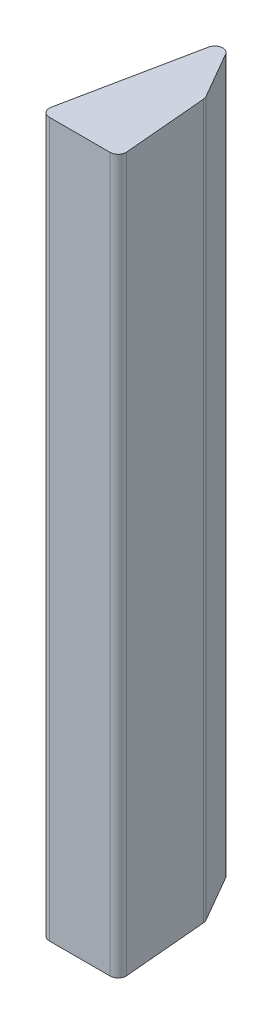
from build123d import *

# Parameters (mm, degrees)
EXTRUDE_1_DEPTH = 450


with BuildPart() as part:
    # Эскиз1 → Бобышка-Вытянуть1 (new body)
    with BuildSketch(Plane(origin=(0, 0, 0), x_dir=(1, 0, 0), z_dir=(0, 1, 0))):
        with BuildLine():
            Line((-43.879004349, 0), (-5.456542505, 0))
            ThreePointArc((-5.456542505, 0), (-1.770155821, 1.622048962), (-0.475569015, 5.435778714))
            Line((-0.475569015, 5.435778714), (-5.13273475, 58.667426648))
            ThreePointArc((-5.13273475, 58.667426648), (-5.345123487, 59.735176932), (-5.783581221, 60.731647934))
            Line((-5.783581221, 60.731647934), (-22.729344565, 90.082571018))
            ThreePointArc((-22.729344565, 90.082571018), (-27.862670313, 92.51763655), (-31.958887312, 88.580431491))
            Line((-31.958887312, 88.580431491), (-48.778420077, 5.997860473))
            ThreePointArc((-48.778420077, 5.997860473), (-47.751297104, 1.836876731), (-43.879004349, 0))
        make_face()
    extrude(amount=EXTRUDE_1_DEPTH)


solid = part.part
